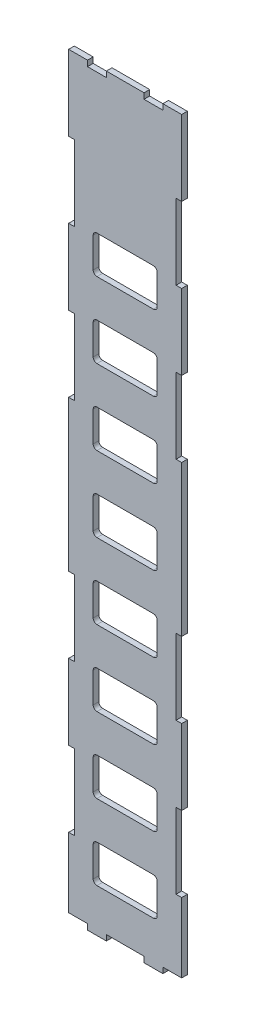
from build123d import *

# Parameters (mm, degrees)
SKETCH1_W           = 60
SKETCH1_H           = 400
BOSS_EXTRUDE1_DEPTH = 3
SKETCH2_W           = 3
SKETCH2_H           = 40
SKETCH2_W_2         = 10
SKETCH2_H_2         = 3
SKETCH2_W_3         = 7
SKETCH2_W_4         = 20
CUT_EXTRUDE3_DEPTH  = 3
SKETCH3_W           = 3
SKETCH3_H           = 3
CUT_EXTRUDE4_DEPTH  = 3
SKETCH4_W           = 34
SKETCH4_H           = 20
CUT_EXTRUDE5_DEPTH  = 3
FILLET1_R           = 2


with BuildPart() as part:
    # Sketch1 → Boss-Extrude1 (new body)
    with BuildSketch(Plane.XY):
        Rectangle(SKETCH1_W, SKETCH1_H)
    extrude(amount=BOSS_EXTRUDE1_DEPTH)

    # Sketch2 → Cut-Extrude3 (cut)
    with BuildSketch(Plane.XY.offset(3)):
        with Locations((-28.5, 60)):
            Rectangle(SKETCH2_W, SKETCH2_H)
        with Locations((-28.5, -60)):
            Rectangle(SKETCH2_W, SKETCH2_H)
        with Locations((-28.5, 140)):
            Rectangle(SKETCH2_W, SKETCH2_H)
        with Locations((-28.5, -140)):
            Rectangle(SKETCH2_W, SKETCH2_H)
        with Locations((-15, 198.5)):
            Rectangle(SKETCH2_W_2, SKETCH2_H_2)
        with Locations((-23.5, -198.5)):
            Rectangle(SKETCH2_W_3, SKETCH2_H_2)
        with Locations((15, 198.5)):
            Rectangle(SKETCH2_W_2, SKETCH2_H_2)
        with Locations((0, -198.5)):
            Rectangle(SKETCH2_W_4, SKETCH2_H_2)
        with Locations((23.5, -198.5)):
            Rectangle(SKETCH2_W_3, SKETCH2_H_2)
        with Locations((28.5, 140)):
            Rectangle(SKETCH2_W, SKETCH2_H)
        with Locations((28.5, -140)):
            Rectangle(SKETCH2_W, SKETCH2_H)
        with Locations((28.5, 60)):
            Rectangle(SKETCH2_W, SKETCH2_H)
        with Locations((28.5, -60)):
            Rectangle(SKETCH2_W, SKETCH2_H)
    extrude(amount=-CUT_EXTRUDE3_DEPTH, mode=Mode.SUBTRACT)

    # Sketch3 → Cut-Extrude4 (cut)
    with BuildSketch(Plane.XY.offset(3)):
        with Locations((-28.5, -198.5)):
            Rectangle(SKETCH3_W, SKETCH3_H)
        with Locations((28.5, -198.5)):
            Rectangle(SKETCH3_W, SKETCH3_H)
    extrude(amount=-CUT_EXTRUDE4_DEPTH, mode=Mode.SUBTRACT)

    # Sketch4 → Cut-Extrude5 (cut)
    with BuildSketch(Plane.XY.offset(3)):
        with Locations((0, -167)):
            Rectangle(SKETCH4_W, SKETCH4_H)
        with Locations((0, -127)):
            Rectangle(SKETCH4_W, SKETCH4_H)
        with Locations((0, -87)):
            Rectangle(SKETCH4_W, SKETCH4_H)
        with Locations((0, -47)):
            Rectangle(SKETCH4_W, SKETCH4_H)
        with Locations((0, -7)):
            Rectangle(SKETCH4_W, SKETCH4_H)
        with Locations((0, 33)):
            Rectangle(SKETCH4_W, SKETCH4_H)
        with Locations((0, 73)):
            Rectangle(SKETCH4_W, SKETCH4_H)
        with Locations((0, 113)):
            Rectangle(SKETCH4_W, SKETCH4_H)
    extrude(amount=-CUT_EXTRUDE5_DEPTH, mode=Mode.SUBTRACT)

    # Fillet1
    fillet1_edges = [part.edges().sort_by_distance(p)[0] for p in [
        (17, -157, 1.5),
        (17, -177, 1.5),
        (-17, -177, 1.5),
        (-17, -157, 1.5),
        (17, -117, 1.5),
        (17, -137, 1.5),
        (-17, -137, 1.5),
        (-17, -117, 1.5),
        (17, -77, 1.5),
        (17, -97, 1.5),
        (-17, -97, 1.5),
        (-17, -77, 1.5),
        (17, -37, 1.5),
        (17, -57, 1.5),
        (-17, -57, 1.5),
        (-17, -37, 1.5),
        (17, 3, 1.5),
        (17, -17, 1.5),
        (-17, -17, 1.5),
        (-17, 3, 1.5),
        (17, 43, 1.5),
        (17, 23, 1.5),
        (-17, 23, 1.5),
        (-17, 43, 1.5),
        (17, 83, 1.5),
        (17, 63, 1.5),
        (-17, 63, 1.5),
        (-17, 83, 1.5),
        (17, 123, 1.5),
        (17, 103, 1.5),
        (-17, 103, 1.5),
        (-17, 123, 1.5),
    ]]
    fillet(fillet1_edges, radius=FILLET1_R)


solid = part.part
